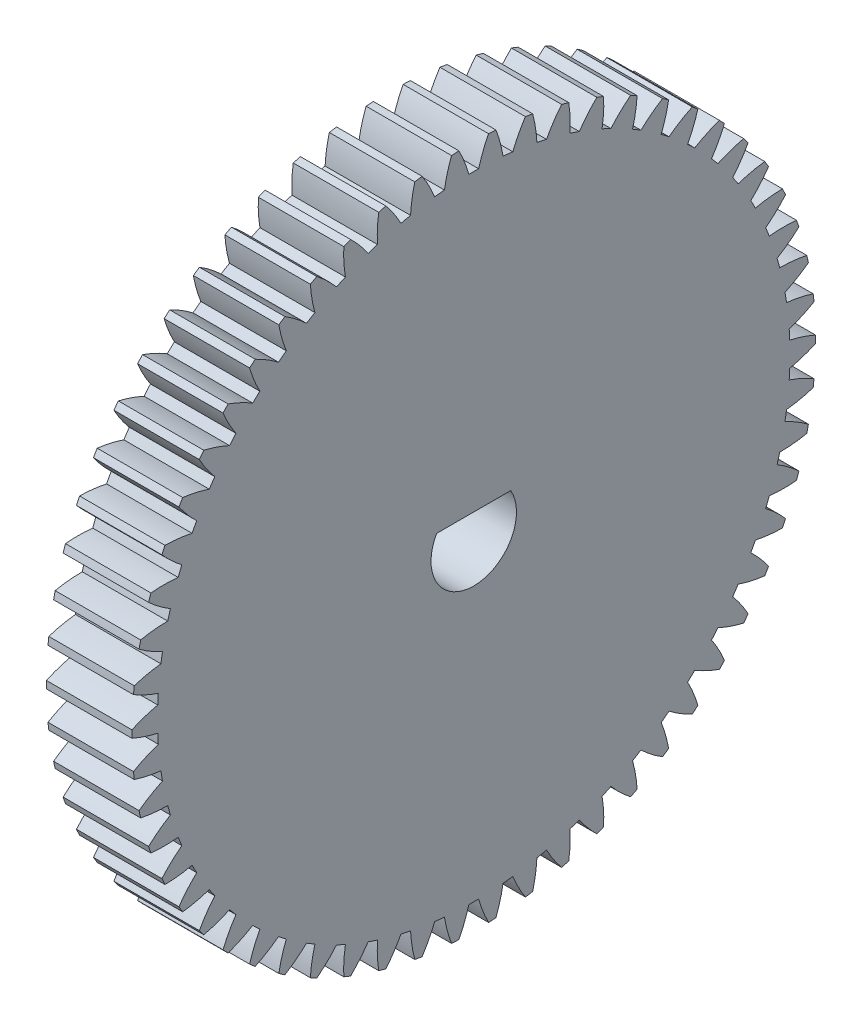
from build123d import *

# Parameters (mm, degrees)
SKETCH1_R           = 3
BOSS_EXTRUDE1_DEPTH = 6
BOSS_EXTRUDE2_DEPTH = 6


with BuildPart() as part:
    # Sketch1 → Boss-Extrude1 (new body)
    with BuildSketch(Plane(origin=(6, 0, 0), x_dir=(0, 0, -1), z_dir=(1, 0, 0))):
        with BuildLine():
            ThreePointArc((2.742266848, 22.028971232), (2.40013409, 22.068868511), (2.05742347, 22.103452438))
            ThreePointArc((2.05742347, 22.103452438), (1.854935421, 23.039368772), (1.557080098, 23.949436352))
            ThreePointArc((1.557080098, 23.949436352), (1.299333806, 23.964801932), (1.041437123, 23.977393702))
            ThreePointArc((1.041437123, 23.977393702), (0.646932226, 23.104864802), (0.344440816, 22.196327659))
            ThreePointArc((0.344440816, 22.196327659), (0, 22.199), (-0.344440816, 22.196327659))
            ThreePointArc((-0.344440816, 22.196327659), (-0.646932226, 23.104864802), (-1.041437123, 23.977393702))
            ThreePointArc((-1.041437123, 23.977393702), (-1.299333806, 23.964801932), (-1.557080098, 23.949436352))
            ThreePointArc((-1.557080098, 23.949436352), (-1.854935421, 23.039368772), (-2.05742347, 22.103452438))
            ThreePointArc((-2.05742347, 22.103452438), (-2.40013409, 22.068868511), (-2.742266848, 22.028971232))
            ThreePointArc((-2.742266848, 22.028971232), (-3.141215185, 22.899477417), (-3.627744445, 23.724238033))
            ThreePointArc((-3.627744445, 23.724238033), (-3.882767917, 23.683836541), (-4.137341978, 23.640693758))
            ThreePointArc((-4.137341978, 23.640693758), (-4.335055647, 22.703757208), (-4.435166347, 21.751434446))
            ThreePointArc((-4.435166347, 21.751434446), (-4.772128802, 21.679999716), (-5.107942309, 21.603345259))
            ThreePointArc((-5.107942309, 21.603345259), (-5.598670268, 22.425614597), (-6.171519781, 23.192937365))
            ThreePointArc((-6.171519781, 23.192937365), (-6.420680125, 23.12519982), (-6.669097306, 23.054785645))
            ThreePointArc((-6.669097306, 23.054785645), (-6.764351309, 22.101964849), (-6.760910953, 21.144400774))
            ThreePointArc((-6.760910953, 21.144400774), (-7.088174667, 21.036952747), (-7.413731816, 20.924439815))
            ThreePointArc((-7.413731816, 20.924439815), (-7.990486061, 21.688831949), (-8.642939689, 22.389720711))
            ThreePointArc((-8.642939689, 22.389720711), (-8.883315728, 22.295441276), (-9.122663565, 22.198581249))
            ThreePointArc((-9.122663565, 22.198581249), (-9.114341137, 21.24104716), (-9.00739006, 20.289468335))
            ThreePointArc((-9.00739006, 20.289468335), (-9.321118166, 20.147266741), (-9.632602097, 20.000214445))
            ThreePointArc((-9.632602097, 20.000214445), (-10.28862071, 20.697767578), (-11.013029033, 21.324005054))
            ThreePointArc((-11.013029033, 21.324005054), (-11.241802577, 21.204289067), (-11.469274936, 21.082118785))
            ThreePointArc((-11.469274936, 21.082118785), (-11.357473648, 20.131097614), (-11.148265755, 19.19666043))
            ThreePointArc((-11.148265755, 19.19666043), (-11.444780075, 19.021372454), (-11.738538924, 18.841504847))
            ThreePointArc((-11.738538924, 18.841504847), (-12.466130689, 19.464040805), (-13.25400068, 20.008284933))
            ThreePointArc((-13.25400068, 20.008284933), (-13.468489569, 19.864535956), (-13.681419544, 19.718487753))
            ThreePointArc((-13.681419544, 19.718487753), (-13.467450164, 18.785129355), (-13.158438226, 17.878789234))
            ThreePointArc((-13.158438226, 17.878789234), (-13.434262403, 17.672469966), (-13.706852116, 17.461895833))
            ThreePointArc((-13.706852116, 17.461895833), (-14.497486683, 18.002115951), (-15.339581287, 18.457985966))
            ThreePointArc((-15.339581287, 18.457985966), (-15.537270835, 18.291889323), (-15.733162017, 18.123675481))
            ThreePointArc((-15.733162017, 18.123675481), (-15.419533141, 17.21892263), (-15.01434004, 16.35130558))
            ThreePointArc((-15.01434004, 16.35130558), (-15.266240287, 16.116373925), (-15.514464999, 15.877562055))
            ThreePointArc((-15.514464999, 15.877562055), (-16.358872901, 16.329132746), (-17.245319329, 16.69128399))
            ThreePointArc((-17.245319329, 16.69128399), (-17.423891806, 16.504787012), (-17.60044755, 16.316379685))
            ThreePointArc((-17.60044755, 16.316379685), (-17.19083619, 15.45083978), (-16.694212444, 14.632117819))
            ThreePointArc((-16.694212444, 14.632117819), (-16.919235462, 14.371328136), (-17.140184965, 14.107078378))
            ThreePointArc((-17.140184965, 14.107078378), (-18.028466291, 14.464705389), (-18.94887177, 14.728891969))
            ThreePointArc((-18.94887177, 14.728891969), (-19.106233577, 14.524181165), (-19.261383929, 14.317789255))
            ThreePointArc((-19.261383929, 14.317789255), (-18.760592403, 13.50160996), (-18.178360472, 12.741381854))
            ThreePointArc((-18.178360472, 12.741381854), (-18.37386807, 12.457791664), (-18.564951933, 12.171202107))
            ThreePointArc((-18.564951933, 12.171202107), (-19.486692398, 12.430692588), (-20.430266014, 12.593817158))
            ThreePointArc((-20.430266014, 12.593817158), (-20.564572228, 12.373292572), (-20.696498191, 12.151335837))
            ThreePointArc((-20.696498191, 12.151335837), (-20.110397822, 11.394086108), (-19.449383843, 10.701264837))
            ThreePointArc((-19.449383843, 10.701264837), (-19.613083875, 10.398198975), (-19.772061814, 10.092629618))
            ThreePointArc((-19.772061814, 10.092629618), (-20.716454853, 10.250941281), (-21.672134068, 10.311091354))
            ThreePointArc((-21.672134068, 10.311091354), (-21.781810072, 10.077338437), (-21.888964935, 9.842419117))
            ThreePointArc((-21.888964935, 9.842419117), (-21.224427215, 9.152977015), (-20.492380972, 8.535685274))
            ThreePointArc((-20.492380972, 8.535685274), (-20.622354203, 8.21669691), (-20.747362348, 7.895730275))
            ThreePointArc((-20.747362348, 7.895730275), (-21.703335816, 7.95100706), (-22.659916166, 7.907477432))
            ThreePointArc((-22.659916166, 7.907477432), (-22.743676108, 7.663236723), (-22.824803579, 7.418109031))
            ThreePointArc((-22.824803579, 7.418109031), (-22.089619603, 6.804557634), (-21.29512367, 6.270032606))
            ThreePointArc((-21.29512367, 6.270032606), (-21.389846284, 5.938861587), (-21.479419029, 5.606260714))
            ThreePointArc((-21.479419029, 5.606260714), (-22.435765011, 5.557854551), (-23.382031465, 5.411155567))
            ThreePointArc((-23.382031465, 5.411155567), (-23.438893337, 5.159290565), (-23.493042269, 4.906828399))
            ThreePointArc((-23.493042269, 4.906828399), (-22.695831399, 4.376361037), (-21.848200514, 3.930869537))
            ThreePointArc((-21.848200514, 3.930869537), (-21.906561974, 3.591398541), (-21.959649159, 3.251062872))
            ThreePointArc((-21.959649159, 3.251062872), (-22.905155373, 3.099541279), (-23.830013823, 2.851392851))
            ThreePointArc((-23.830013823, 2.851392851), (-23.859310972, 2.594856442), (-23.885846519, 2.338019691))
            ThreePointArc((-23.885846519, 2.338019691), (-23.035955323, 1.896855608), (-22.145127182, 1.545620618))
            ThreePointArc((-22.145127182, 1.545620618), (-22.166443254, 1.201829632), (-22.182422482, 0.85774929))
            ThreePointArc((-22.182422482, 0.85774929), (-23.106003732, 0.604888719), (-23.998611057, 0.25820016))
            ThreePointArc((-23.998611057, 0.25820016), (-24, 0), (-23.998611057, -0.25820016))
            ThreePointArc((-23.998611057, -0.25820016), (-23.106003732, -0.604888719), (-22.182422482, -0.85774929))
            ThreePointArc((-22.182422482, -0.85774929), (-22.166443254, -1.201829632), (-22.145127182, -1.545620618))
            ThreePointArc((-22.145127182, -1.545620618), (-23.035955323, -1.896855608), (-23.885846519, -2.338019691))
            ThreePointArc((-23.885846519, -2.338019691), (-23.859310972, -2.594856442), (-23.830013823, -2.851392851))
            ThreePointArc((-23.830013823, -2.851392851), (-22.905155373, -3.099541279), (-21.959649159, -3.251062872))
            ThreePointArc((-21.959649159, -3.251062872), (-21.906561974, -3.591398541), (-21.848200514, -3.930869537))
            ThreePointArc((-21.848200514, -3.930869537), (-22.695831399, -4.376361037), (-23.493042269, -4.906828399))
            ThreePointArc((-23.493042269, -4.906828399), (-23.438893337, -5.159290565), (-23.382031465, -5.411155567))
            ThreePointArc((-23.382031465, -5.411155567), (-22.435765011, -5.557854551), (-21.479419029, -5.606260714))
            ThreePointArc((-21.479419029, -5.606260714), (-21.389846284, -5.938861587), (-21.29512367, -6.270032606))
            ThreePointArc((-21.29512367, -6.270032606), (-22.089619603, -6.804557634), (-22.824803579, -7.418109031))
            ThreePointArc((-22.824803579, -7.418109031), (-22.743676108, -7.663236723), (-22.659916166, -7.907477432))
            ThreePointArc((-22.659916166, -7.907477432), (-21.703335816, -7.95100706), (-20.747362348, -7.895730275))
            ThreePointArc((-20.747362348, -7.895730275), (-20.622354203, -8.21669691), (-20.492380972, -8.535685274))
            ThreePointArc((-20.492380972, -8.535685274), (-21.224427215, -9.152977015), (-21.888964935, -9.842419117))
            ThreePointArc((-21.888964935, -9.842419117), (-21.781810072, -10.077338437), (-21.672134068, -10.311091354))
            ThreePointArc((-21.672134068, -10.311091354), (-20.716454853, -10.250941281), (-19.772061814, -10.092629618))
            ThreePointArc((-19.772061814, -10.092629618), (-19.613083875, -10.398198975), (-19.449383843, -10.701264837))
            ThreePointArc((-19.449383843, -10.701264837), (-20.110397822, -11.394086108), (-20.696498191, -12.151335837))
            ThreePointArc((-20.696498191, -12.151335837), (-20.564572228, -12.373292572), (-20.430266014, -12.593817158))
            ThreePointArc((-20.430266014, -12.593817158), (-19.486692398, -12.430692588), (-18.564951933, -12.171202107))
            ThreePointArc((-18.564951933, -12.171202107), (-18.37386807, -12.457791664), (-18.178360472, -12.741381854))
            ThreePointArc((-18.178360472, -12.741381854), (-18.760592403, -13.50160996), (-19.261383929, -14.317789255))
            ThreePointArc((-19.261383929, -14.317789255), (-19.106233577, -14.524181165), (-18.94887177, -14.728891969))
            ThreePointArc((-18.94887177, -14.728891969), (-18.028466291, -14.464705389), (-17.140184965, -14.107078378))
            ThreePointArc((-17.140184965, -14.107078378), (-16.919235462, -14.371328136), (-16.694212444, -14.632117819))
            ThreePointArc((-16.694212444, -14.632117819), (-17.19083619, -15.45083978), (-17.60044755, -16.316379685))
            ThreePointArc((-17.60044755, -16.316379685), (-17.423891806, -16.504787012), (-17.245319329, -16.69128399))
            ThreePointArc((-17.245319329, -16.69128399), (-16.358872901, -16.329132746), (-15.514464999, -15.877562055))
            ThreePointArc((-15.514464999, -15.877562055), (-15.266240287, -16.116373925), (-15.01434004, -16.35130558))
            ThreePointArc((-15.01434004, -16.35130558), (-15.419533141, -17.21892263), (-15.733162017, -18.123675481))
            ThreePointArc((-15.733162017, -18.123675481), (-15.537270835, -18.291889323), (-15.339581287, -18.457985966))
            ThreePointArc((-15.339581287, -18.457985966), (-14.497486683, -18.002115951), (-13.706852116, -17.461895833))
            ThreePointArc((-13.706852116, -17.461895833), (-13.434262403, -17.672469966), (-13.158438226, -17.878789234))
            ThreePointArc((-13.158438226, -17.878789234), (-13.467450164, -18.785129355), (-13.681419544, -19.718487753))
            ThreePointArc((-13.681419544, -19.718487753), (-13.468489569, -19.864535956), (-13.25400068, -20.008284933))
            ThreePointArc((-13.25400068, -20.008284933), (-12.466130689, -19.464040805), (-11.738538924, -18.841504847))
            ThreePointArc((-11.738538924, -18.841504847), (-11.444780075, -19.021372454), (-11.148265755, -19.19666043))
            ThreePointArc((-11.148265755, -19.19666043), (-11.357473648, -20.131097614), (-11.469274936, -21.082118785))
            ThreePointArc((-11.469274936, -21.082118785), (-11.241802577, -21.204289067), (-11.013029033, -21.324005054))
            ThreePointArc((-11.013029033, -21.324005054), (-10.28862071, -20.697767578), (-9.632602097, -20.000214445))
            ThreePointArc((-9.632602097, -20.000214445), (-9.321118166, -20.147266741), (-9.00739006, -20.289468335))
            ThreePointArc((-9.00739006, -20.289468335), (-9.114341137, -21.24104716), (-9.122663565, -22.198581249))
            ThreePointArc((-9.122663565, -22.198581249), (-8.883315728, -22.295441276), (-8.642939689, -22.389720711))
            ThreePointArc((-8.642939689, -22.389720711), (-7.990486061, -21.688831949), (-7.413731816, -20.924439815))
            ThreePointArc((-7.413731816, -20.924439815), (-7.088174667, -21.036952747), (-6.760910953, -21.144400774))
            ThreePointArc((-6.760910953, -21.144400774), (-6.764351309, -22.101964849), (-6.669097306, -23.054785645))
            ThreePointArc((-6.669097306, -23.054785645), (-6.420680125, -23.12519982), (-6.171519781, -23.192937365))
            ThreePointArc((-6.171519781, -23.192937365), (-5.598670268, -22.425614597), (-5.107942309, -21.603345259))
            ThreePointArc((-5.107942309, -21.603345259), (-4.772128802, -21.679999716), (-4.435166347, -21.751434446))
            ThreePointArc((-4.435166347, -21.751434446), (-4.335055647, -22.703757208), (-4.137341978, -23.640693758))
            ThreePointArc((-4.137341978, -23.640693758), (-3.882767917, -23.683836541), (-3.627744445, -23.724238033))
            ThreePointArc((-3.627744445, -23.724238033), (-3.141215185, -22.899477417), (-2.742266848, -22.028971232))
            ThreePointArc((-2.742266848, -22.028971232), (-2.40013409, -22.068868511), (-2.05742347, -22.103452438))
            ThreePointArc((-2.05742347, -22.103452438), (-1.854935421, -23.039368772), (-1.557080098, -23.949436352))
            ThreePointArc((-1.557080098, -23.949436352), (-1.299333806, -23.964801932), (-1.041437123, -23.977393702))
            ThreePointArc((-1.041437123, -23.977393702), (-0.646932226, -23.104864802), (-0.344440816, -22.196327659))
            ThreePointArc((-0.344440816, -22.196327659), (0, -22.199), (0.344440816, -22.196327659))
            ThreePointArc((0.344440816, -22.196327659), (0.646932226, -23.104864802), (1.041437123, -23.977393702))
            ThreePointArc((1.041437123, -23.977393702), (1.299333806, -23.964801932), (1.557080098, -23.949436352))
            ThreePointArc((1.557080098, -23.949436352), (1.854935421, -23.039368772), (2.05742347, -22.103452438))
            ThreePointArc((2.05742347, -22.103452438), (2.40013409, -22.068868511), (2.742266848, -22.028971232))
            ThreePointArc((2.742266848, -22.028971232), (3.141215185, -22.899477417), (3.627744445, -23.724238033))
            ThreePointArc((3.627744445, -23.724238033), (3.882767917, -23.683836541), (4.137341978, -23.640693758))
            ThreePointArc((4.137341978, -23.640693758), (4.335055647, -22.703757208), (4.435166347, -21.751434446))
            ThreePointArc((4.435166347, -21.751434446), (4.772128802, -21.679999716), (5.107942309, -21.603345259))
            ThreePointArc((5.107942309, -21.603345259), (5.598670268, -22.425614597), (6.171519781, -23.192937365))
            ThreePointArc((6.171519781, -23.192937365), (6.420680125, -23.12519982), (6.669097306, -23.054785645))
            ThreePointArc((6.669097306, -23.054785645), (6.764351309, -22.101964849), (6.760910953, -21.144400774))
            ThreePointArc((6.760910953, -21.144400774), (7.088174667, -21.036952747), (7.413731816, -20.924439815))
            ThreePointArc((7.413731816, -20.924439815), (7.990486061, -21.688831949), (8.642939689, -22.389720711))
            ThreePointArc((8.642939689, -22.389720711), (8.883315728, -22.295441276), (9.122663565, -22.198581249))
            ThreePointArc((9.122663565, -22.198581249), (9.114341137, -21.24104716), (9.00739006, -20.289468335))
            ThreePointArc((9.00739006, -20.289468335), (9.321118166, -20.147266741), (9.632602097, -20.000214445))
            ThreePointArc((9.632602097, -20.000214445), (10.28862071, -20.697767578), (11.013029033, -21.324005054))
            ThreePointArc((11.013029033, -21.324005054), (11.241802577, -21.204289067), (11.469274936, -21.082118785))
            ThreePointArc((11.469274936, -21.082118785), (11.357473648, -20.131097614), (11.148265755, -19.19666043))
            ThreePointArc((11.148265755, -19.19666043), (11.444780075, -19.021372454), (11.738538924, -18.841504847))
            ThreePointArc((11.738538924, -18.841504847), (12.466130689, -19.464040805), (13.25400068, -20.008284933))
            ThreePointArc((13.25400068, -20.008284933), (13.468489569, -19.864535956), (13.681419544, -19.718487753))
            ThreePointArc((13.681419544, -19.718487753), (13.467450164, -18.785129355), (13.158438226, -17.878789234))
            ThreePointArc((13.158438226, -17.878789234), (13.434262403, -17.672469966), (13.706852116, -17.461895833))
            ThreePointArc((13.706852116, -17.461895833), (14.497486683, -18.002115951), (15.339581287, -18.457985966))
            ThreePointArc((15.339581287, -18.457985966), (15.537270835, -18.291889323), (15.733162017, -18.123675481))
            ThreePointArc((15.733162017, -18.123675481), (15.419533141, -17.21892263), (15.01434004, -16.35130558))
            ThreePointArc((15.01434004, -16.35130558), (15.266240287, -16.116373925), (15.514464999, -15.877562055))
            ThreePointArc((15.514464999, -15.877562055), (16.358872901, -16.329132746), (17.245319329, -16.69128399))
            ThreePointArc((17.245319329, -16.69128399), (17.423891806, -16.504787012), (17.60044755, -16.316379685))
            ThreePointArc((17.60044755, -16.316379685), (17.19083619, -15.45083978), (16.694212444, -14.632117819))
            ThreePointArc((16.694212444, -14.632117819), (16.919235462, -14.371328136), (17.140184965, -14.107078378))
            ThreePointArc((17.140184965, -14.107078378), (18.028466291, -14.464705389), (18.94887177, -14.728891969))
            ThreePointArc((18.94887177, -14.728891969), (19.106233577, -14.524181165), (19.261383929, -14.317789255))
            ThreePointArc((19.261383929, -14.317789255), (18.760592403, -13.50160996), (18.178360472, -12.741381854))
            ThreePointArc((18.178360472, -12.741381854), (18.37386807, -12.457791664), (18.564951933, -12.171202107))
            ThreePointArc((18.564951933, -12.171202107), (19.486692398, -12.430692588), (20.430266014, -12.593817158))
            ThreePointArc((20.430266014, -12.593817158), (20.564572228, -12.373292572), (20.696498191, -12.151335837))
            ThreePointArc((20.696498191, -12.151335837), (20.110397822, -11.394086108), (19.449383843, -10.701264837))
            ThreePointArc((19.449383843, -10.701264837), (19.613083875, -10.398198975), (19.772061814, -10.092629618))
            ThreePointArc((19.772061814, -10.092629618), (20.716454853, -10.250941281), (21.672134068, -10.311091354))
            ThreePointArc((21.672134068, -10.311091354), (21.781810072, -10.077338437), (21.888964935, -9.842419117))
            ThreePointArc((21.888964935, -9.842419117), (21.224427215, -9.152977015), (20.492380972, -8.535685274))
            ThreePointArc((20.492380972, -8.535685274), (20.622354203, -8.21669691), (20.747362348, -7.895730275))
            ThreePointArc((20.747362348, -7.895730275), (21.703335816, -7.95100706), (22.659916166, -7.907477432))
            ThreePointArc((22.659916166, -7.907477432), (22.743676108, -7.663236723), (22.824803579, -7.418109031))
            ThreePointArc((22.824803579, -7.418109031), (22.089619603, -6.804557634), (21.29512367, -6.270032606))
            ThreePointArc((21.29512367, -6.270032606), (21.389846284, -5.938861587), (21.479419029, -5.606260714))
            ThreePointArc((21.479419029, -5.606260714), (22.435765011, -5.557854551), (23.382031465, -5.411155567))
            ThreePointArc((23.382031465, -5.411155567), (23.438893337, -5.159290565), (23.493042269, -4.906828399))
            ThreePointArc((23.493042269, -4.906828399), (22.695831399, -4.376361037), (21.848200514, -3.930869537))
            ThreePointArc((21.848200514, -3.930869537), (21.906561974, -3.591398541), (21.959649159, -3.251062872))
            ThreePointArc((21.959649159, -3.251062872), (22.905155373, -3.099541279), (23.830013823, -2.851392851))
            ThreePointArc((23.830013823, -2.851392851), (23.859310972, -2.594856442), (23.885846519, -2.338019691))
            ThreePointArc((23.885846519, -2.338019691), (23.035955323, -1.896855608), (22.145127182, -1.545620618))
            ThreePointArc((22.145127182, -1.545620618), (22.166443254, -1.201829632), (22.182422482, -0.85774929))
            ThreePointArc((22.182422482, -0.85774929), (23.106003732, -0.604888719), (23.998611057, -0.25820016))
            ThreePointArc((23.998611057, -0.25820016), (24, 0), (23.998611057, 0.25820016))
            ThreePointArc((23.998611057, 0.25820016), (23.106003732, 0.604888719), (22.182422482, 0.85774929))
            ThreePointArc((22.182422482, 0.85774929), (22.166443254, 1.201829632), (22.145127182, 1.545620618))
            ThreePointArc((22.145127182, 1.545620618), (23.035955323, 1.896855608), (23.885846519, 2.338019691))
            ThreePointArc((23.885846519, 2.338019691), (23.859310972, 2.594856442), (23.830013823, 2.851392851))
            ThreePointArc((23.830013823, 2.851392851), (22.905155373, 3.099541279), (21.959649159, 3.251062872))
            ThreePointArc((21.959649159, 3.251062872), (21.906561974, 3.591398541), (21.848200514, 3.930869537))
            ThreePointArc((21.848200514, 3.930869537), (22.695831399, 4.376361037), (23.493042269, 4.906828399))
            ThreePointArc((23.493042269, 4.906828399), (23.438893337, 5.159290565), (23.382031465, 5.411155567))
            ThreePointArc((23.382031465, 5.411155567), (22.435765011, 5.557854551), (21.479419029, 5.606260714))
            ThreePointArc((21.479419029, 5.606260714), (21.389846284, 5.938861587), (21.29512367, 6.270032606))
            ThreePointArc((21.29512367, 6.270032606), (22.089619603, 6.804557634), (22.824803579, 7.418109031))
            ThreePointArc((22.824803579, 7.418109031), (22.743676108, 7.663236723), (22.659916166, 7.907477432))
            ThreePointArc((22.659916166, 7.907477432), (21.703335816, 7.95100706), (20.747362348, 7.895730275))
            ThreePointArc((20.747362348, 7.895730275), (20.622354203, 8.21669691), (20.492380972, 8.535685274))
            ThreePointArc((20.492380972, 8.535685274), (21.224427215, 9.152977015), (21.888964935, 9.842419117))
            ThreePointArc((21.888964935, 9.842419117), (21.781810072, 10.077338437), (21.672134068, 10.311091354))
            ThreePointArc((21.672134068, 10.311091354), (20.716454853, 10.250941281), (19.772061814, 10.092629618))
            ThreePointArc((19.772061814, 10.092629618), (19.613083875, 10.398198975), (19.449383843, 10.701264837))
            ThreePointArc((19.449383843, 10.701264837), (20.110397822, 11.394086108), (20.696498191, 12.151335837))
            ThreePointArc((20.696498191, 12.151335837), (20.564572228, 12.373292572), (20.430266014, 12.593817158))
            ThreePointArc((20.430266014, 12.593817158), (19.486692398, 12.430692588), (18.564951933, 12.171202107))
            ThreePointArc((18.564951933, 12.171202107), (18.37386807, 12.457791664), (18.178360472, 12.741381854))
            ThreePointArc((18.178360472, 12.741381854), (18.760592403, 13.50160996), (19.261383929, 14.317789255))
            ThreePointArc((19.261383929, 14.317789255), (19.106233577, 14.524181165), (18.94887177, 14.728891969))
            ThreePointArc((18.94887177, 14.728891969), (18.028466291, 14.464705389), (17.140184965, 14.107078378))
            ThreePointArc((17.140184965, 14.107078378), (16.919235462, 14.371328136), (16.694212444, 14.632117819))
            ThreePointArc((16.694212444, 14.632117819), (17.19083619, 15.45083978), (17.60044755, 16.316379685))
            ThreePointArc((17.60044755, 16.316379685), (17.423891806, 16.504787012), (17.245319329, 16.69128399))
            ThreePointArc((17.245319329, 16.69128399), (16.358872901, 16.329132746), (15.514464999, 15.877562055))
            ThreePointArc((15.514464999, 15.877562055), (15.266240287, 16.116373925), (15.01434004, 16.35130558))
            ThreePointArc((15.01434004, 16.35130558), (15.419533141, 17.21892263), (15.733162017, 18.123675481))
            ThreePointArc((15.733162017, 18.123675481), (15.537270835, 18.291889323), (15.339581287, 18.457985966))
            ThreePointArc((15.339581287, 18.457985966), (14.497486683, 18.002115951), (13.706852116, 17.461895833))
            ThreePointArc((13.706852116, 17.461895833), (13.434262403, 17.672469966), (13.158438226, 17.878789234))
            ThreePointArc((13.158438226, 17.878789234), (13.467450164, 18.785129355), (13.681419544, 19.718487753))
            ThreePointArc((13.681419544, 19.718487753), (13.468489569, 19.864535956), (13.25400068, 20.008284933))
            ThreePointArc((13.25400068, 20.008284933), (12.466130689, 19.464040805), (11.738538924, 18.841504847))
            ThreePointArc((11.738538924, 18.841504847), (11.444780075, 19.021372454), (11.148265755, 19.19666043))
            ThreePointArc((11.148265755, 19.19666043), (11.357473648, 20.131097614), (11.469274936, 21.082118785))
            ThreePointArc((11.469274936, 21.082118785), (11.241802577, 21.204289067), (11.013029033, 21.324005054))
            ThreePointArc((11.013029033, 21.324005054), (10.28862071, 20.697767578), (9.632602097, 20.000214445))
            ThreePointArc((9.632602097, 20.000214445), (9.321118166, 20.147266741), (9.00739006, 20.289468335))
            ThreePointArc((9.00739006, 20.289468335), (9.114341137, 21.24104716), (9.122663565, 22.198581249))
            ThreePointArc((9.122663565, 22.198581249), (8.883315728, 22.295441276), (8.642939689, 22.389720711))
            ThreePointArc((8.642939689, 22.389720711), (7.990486061, 21.688831949), (7.413731816, 20.924439815))
            ThreePointArc((7.413731816, 20.924439815), (7.088174667, 21.036952747), (6.760910953, 21.144400774))
            ThreePointArc((6.760910953, 21.144400774), (6.764351309, 22.101964849), (6.669097306, 23.054785645))
            ThreePointArc((6.669097306, 23.054785645), (6.420680125, 23.12519982), (6.171519781, 23.192937365))
            ThreePointArc((6.171519781, 23.192937365), (5.598670268, 22.425614597), (5.107942309, 21.603345259))
            ThreePointArc((5.107942309, 21.603345259), (4.772128802, 21.679999716), (4.435166347, 21.751434446))
            ThreePointArc((4.435166347, 21.751434446), (4.335055647, 22.703757208), (4.137341978, 23.640693758))
            ThreePointArc((4.137341978, 23.640693758), (3.882767917, 23.683836541), (3.627744445, 23.724238033))
            ThreePointArc((3.627744445, 23.724238033), (3.141215185, 22.899477417), (2.742266848, 22.028971232))
        make_face()
        Circle(SKETCH1_R, mode=Mode.SUBTRACT)
    extrude(amount=-BOSS_EXTRUDE1_DEPTH)

    # Sketch2 → Boss-Extrude2 (add)
    with BuildSketch(Plane(origin=(6, 0, 0), x_dir=(0, 0, -1), z_dir=(1, 0, 0))):
        with BuildLine():
            Line((-2.598076211, 1.5), (2.598076211, 1.5))
            ThreePointArc((2.598076211, 1.5), (0, 3), (-2.598076211, 1.5))
        make_face()
    extrude(amount=-BOSS_EXTRUDE2_DEPTH)


solid = part.part
